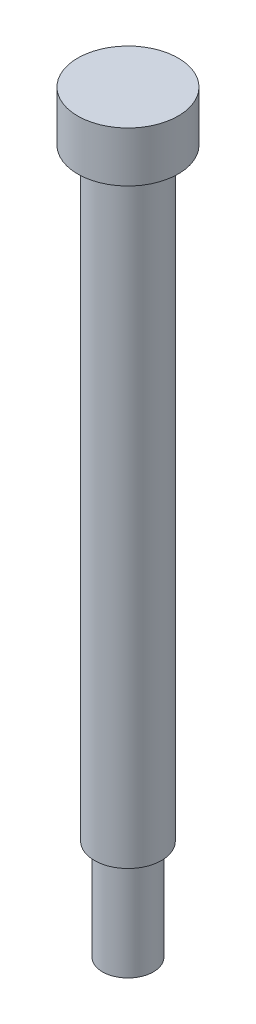
from build123d import *


with BuildPart() as part:
    # profile → Base-Revolve (revolve)
    with BuildSketch(Plane.XY):
        Polygon((0, 4.7625), (4.7625, 4.7625), (4.7625, 0), (3.175, 0), (3.175, -57.15), (2.413, -57.15), (2.413, -66.675), (0, -66.675), align=None)
    revolve(axis=Axis((0, 24.832359952, 0), (0, -1, 0)))


solid = part.part
